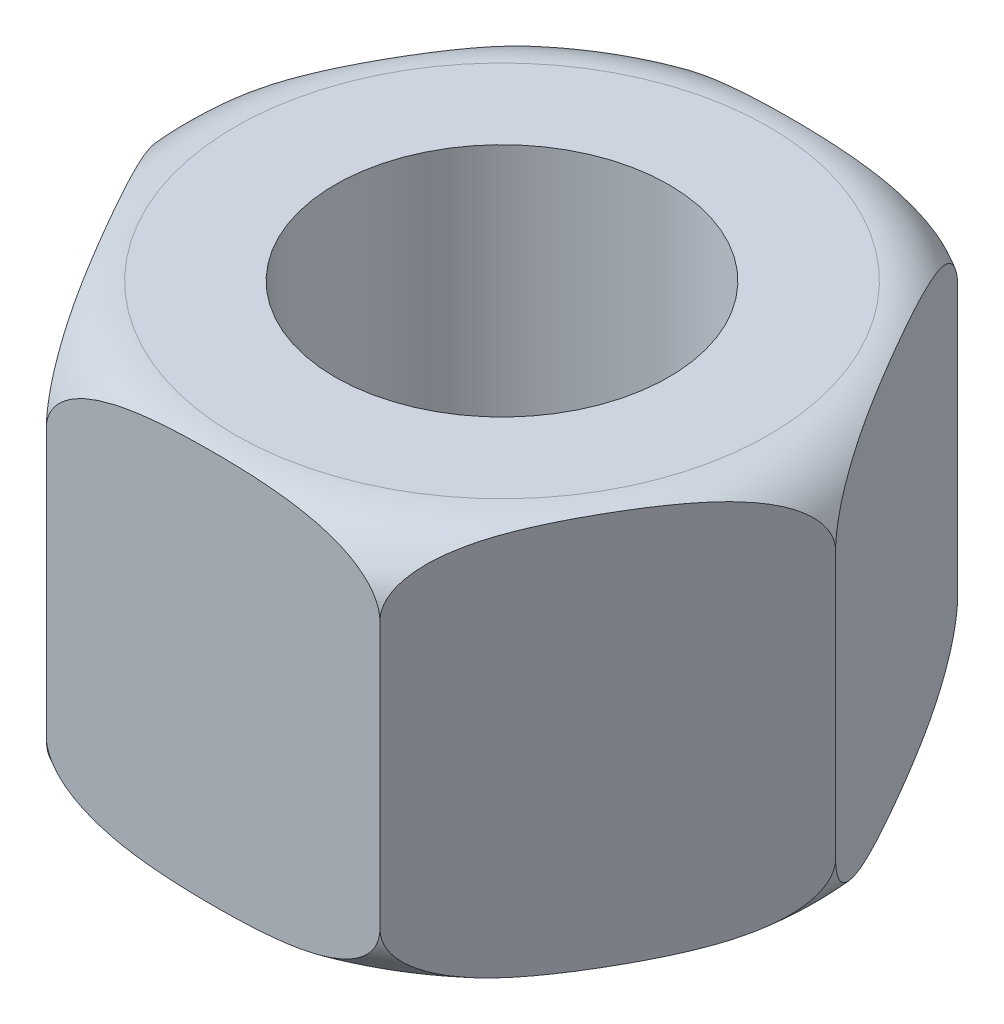
from build123d import *

# Parameters (mm, degrees)
BOSS_EXTRUDE1_DEPTH = 1.5
SKETCH2_R           = 1.25
CUT_EXTRUDE1_DEPTH  = 4


with BuildPart() as part:
    # Sketch1 → Boss-Extrude1 (new body, symmetric)
    with BuildSketch(Plane(origin=(0, 0, 0), x_dir=(1, 0, 0), z_dir=(0, 1, 0))):
        Polygon((2.5, 0), (1.25, 2.165063509), (-1.25, 2.165063509), (-2.5, 0), (-1.25, -2.165063509), (1.25, -2.165063509), align=None)
    extrude(amount=BOSS_EXTRUDE1_DEPTH, both=True)

    # Sketch2 → Cut-Extrude1 (cut, through all)
    with BuildSketch(Plane(origin=(0, 1.5, 0), x_dir=(1, 0, 0), z_dir=(0, 1, 0))):
        Circle(SKETCH2_R)
    extrude(amount=-CUT_EXTRUDE1_DEPTH, mode=Mode.SUBTRACT)

    # Sketch3 → Cut-Revolve1 (revolve, cut)
    with BuildSketch(Plane.XY):
        with BuildLine():
            Line((-2, 1.5), (-1.792019958, 1.5))
            Line((-1.792019958, 1.5), (-2.45433601, 1.868931602))
            Line((-2.45433601, 1.868931602), (-2.872282185, 1.266409158))
            Line((-2.872282185, 1.266409158), (-2.5, 0.870574679))
            Line((-2.5, 0.870574679), (-2.5, 1))
            ThreePointArc((-2.5, 1), (-2.353553391, 1.353553391), (-2, 1.5))
        make_face()
        with BuildLine():
            Line((-2.5, -1), (-2.5, -0.713166542))
            Line((-2.5, -0.713166542), (-2.9927012, -1.5))
            Line((-2.9927012, -1.5), (-2.45433601, -1.839605404))
            Line((-2.45433601, -1.839605404), (-1.859208979, -1.5))
            Line((-1.859208979, -1.5), (-2, -1.5))
            ThreePointArc((-2, -1.5), (-2.353553391, -1.353553391), (-2.5, -1))
        make_face()
    revolve(axis=Axis((0, 0, 0), (0, 1, 0)), mode=Mode.SUBTRACT)


solid = part.part
